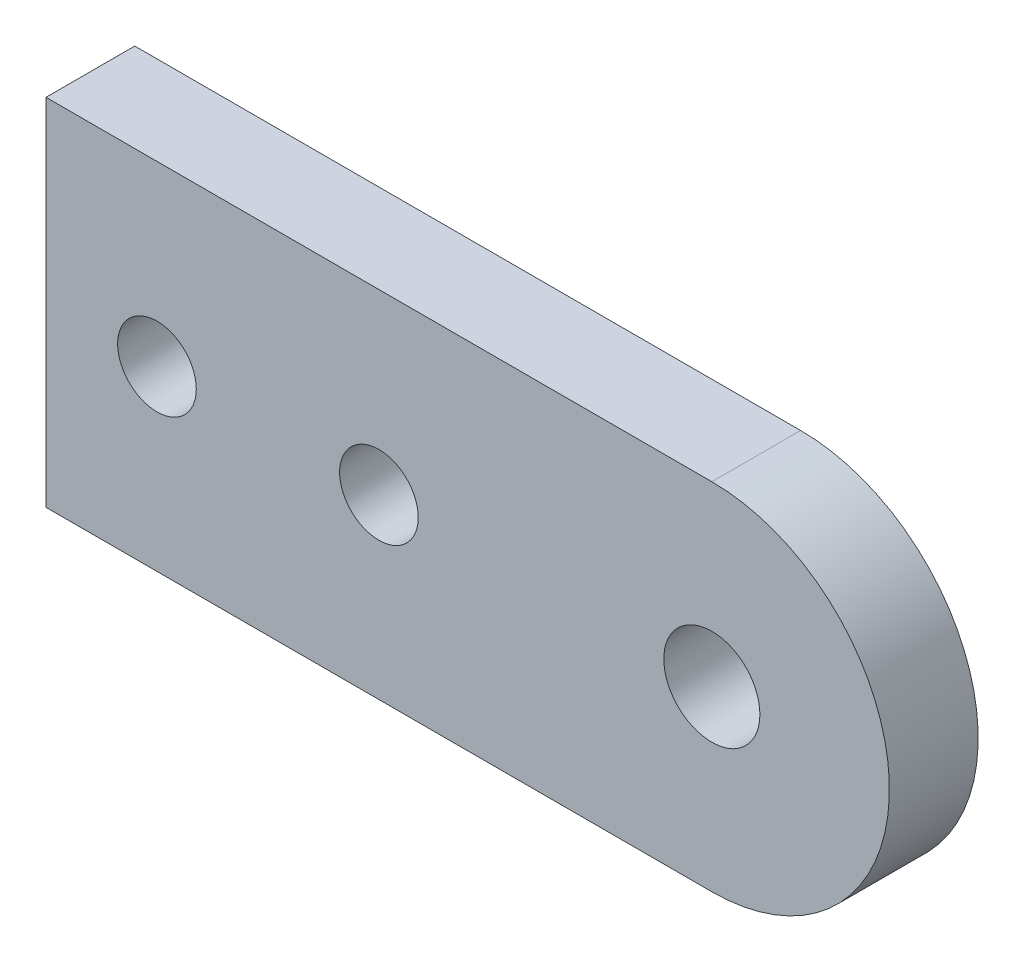
from build123d import *

# Parameters (mm, degrees)
BOSS_EXTRUDE1_DEPTH  = 5.08
M5_CLEARANCE_HOLE1_D = 5.5
M4_CLEARANCE_HOLE1_D = 4.5


with BuildPart() as part:
    # Sketch1 → Boss-Extrude1 (new body)
    with BuildSketch(Plane.XY):
        with BuildLine():
            Line((0, 10.16), (0, -10.16))
            Line((0, -10.16), (38.1, -10.16))
            ThreePointArc((38.1, -10.16), (48.26, 0), (38.1, 10.16))
            Line((38.1, 10.16), (0, 10.16))
        make_face()
    extrude(amount=BOSS_EXTRUDE1_DEPTH)

    # M5 Clearance Hole1 (through all)
    with Locations(Plane.XY.offset(5.08)):
        with Locations((38.1, 0)):
            Hole(M5_CLEARANCE_HOLE1_D / 2)

    # M4 Clearance Hole1 (through all)
    with Locations(Plane.XY.offset(5.08)):
        with Locations((19.0499945, -0.016311357), (6.35, -0.00449174)):
            Hole(M4_CLEARANCE_HOLE1_D / 2)


solid = part.part
